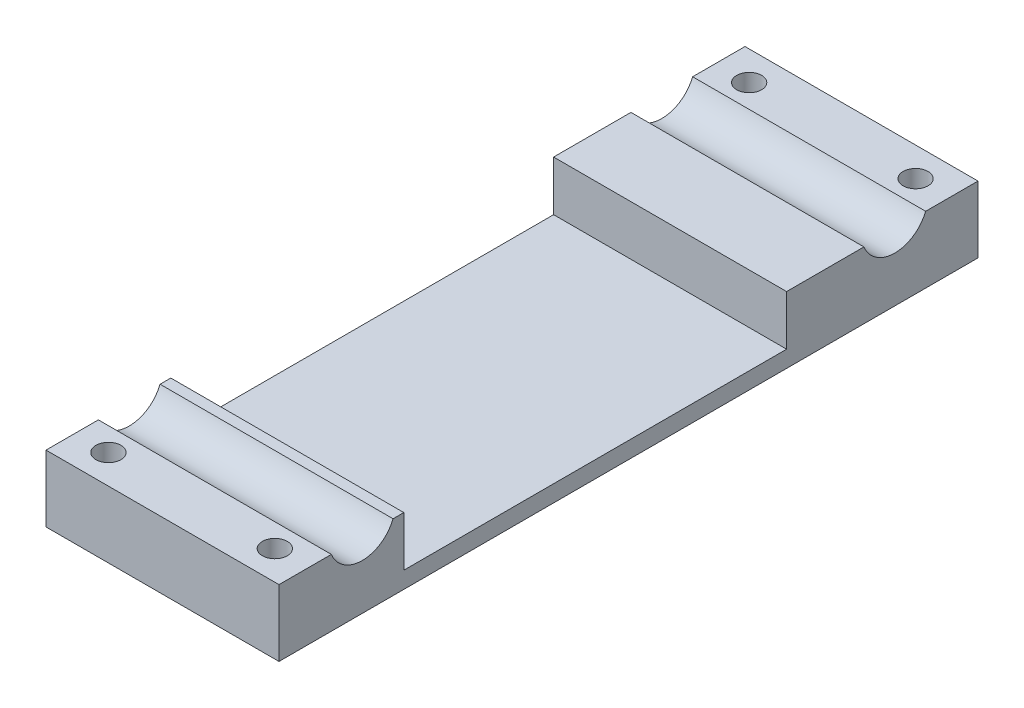
from build123d import *

# Parameters (mm, degrees)
SKETCH1_R               = 1.5
SKETCH1_W               = 28
SKETCH1_H               = 54
BOSS_EXTRUDE1_DEPTH     = 8
SKETCH4_W               = 46
SKETCH4_H               = 6
CUT_EXTRUDE1_DEPTH      = 1
CUT_EXTRUDE1_DEPTH_BACK = 29
SKETCH5_R               = 4
CUT_EXTRUDE2_DEPTH      = 1
CUT_EXTRUDE2_DEPTH_BACK = 29


with BuildPart() as part:
    # Sketch1 → Boss-Extrude1 (new body)
    with BuildSketch(Plane(origin=(0, 12.242650433, 0), x_dir=(1, 0, 0), z_dir=(0, 1, 0))):
        Polygon((-49.268515773, 16.802150236), (-49.268515773, 15.802150236), (-21.268515773, 15.802150236), (-21.268515773, 16.802150236), (-21.268515773, 17.094050992), (-21.268515773, 24.510249479), (-21.268515773, 24.802150236), (-21.268515773, 30.802150236), (-49.268515773, 30.802150236), (-49.268515773, 24.802150236), (-49.268515773, 24.510249479), (-49.268515773, 17.094050992), align=None)
        with Locations((-45.268515773, 27.302150236)):
            Circle(SKETCH1_R, mode=Mode.SUBTRACT)
        with Locations((-25.268515773, 27.302150236)):
            Circle(SKETCH1_R, mode=Mode.SUBTRACT)
        with Locations((-35.268515773, -11.197849764)):
            Rectangle(SKETCH1_W, SKETCH1_H)
        Polygon((-49.268515773, -47.197849764), (-49.268515773, -53.197849764), (-21.268515773, -53.197849764), (-21.268515773, -47.197849764), (-21.268515773, -46.905949008), (-21.268515773, -39.489750521), (-21.268515773, -39.197849764), (-21.268515773, -38.197849764), (-49.268515773, -38.197849764), (-49.268515773, -39.197849764), (-49.268515773, -39.489750521), (-49.268515773, -46.905949008), align=None)
        with Locations((-45.268515773, -49.697849764)):
            Circle(SKETCH1_R, mode=Mode.SUBTRACT)
        with Locations((-25.268515773, -49.697849764)):
            Circle(SKETCH1_R, mode=Mode.SUBTRACT)
    extrude(amount=-BOSS_EXTRUDE1_DEPTH)

    # Sketch4 → Cut-Extrude1 (cut, two sides)
    with BuildSketch(Plane(origin=(-21.268515773, 0, 0), x_dir=(0, 0, -1), z_dir=(1, 0, 0))) as cut_extrude1_sk:
        with Locations((-15.197849764, 9.242650433)):
            Rectangle(SKETCH4_W, SKETCH4_H)
    extrude(amount=CUT_EXTRUDE1_DEPTH, mode=Mode.SUBTRACT)
    extrude(cut_extrude1_sk.sketch, amount=-CUT_EXTRUDE1_DEPTH_BACK, mode=Mode.SUBTRACT)

    # Sketch5 → Cut-Extrude2 (cut, two sides)
    with BuildSketch(Plane(origin=(-21.268515773, 0, 0), x_dir=(0, 0, -1), z_dir=(1, 0, 0))) as cut_extrude2_sk:
        with Locations((-43.197849764, 13.742650433)):
            Circle(SKETCH5_R)
        with Locations((20.802150236, 13.742650433)):
            Circle(SKETCH5_R)
    extrude(amount=CUT_EXTRUDE2_DEPTH, mode=Mode.SUBTRACT)
    extrude(cut_extrude2_sk.sketch, amount=-CUT_EXTRUDE2_DEPTH_BACK, mode=Mode.SUBTRACT)


solid = part.part
